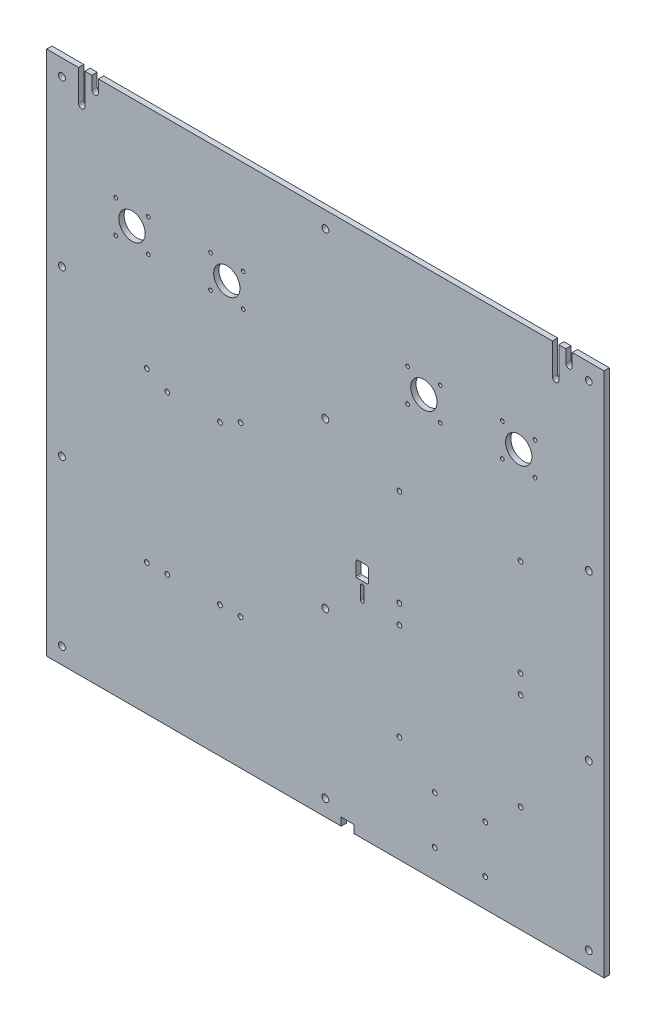
from build123d import *

# Parameters (mm, degrees)
MODEL_R             = 3.25
MODEL_R_2           = 2.25
MODEL_R_3           = 1.75
MODEL_R_4           = 12.5
BOSS_EXTRUDE1_DEPTH = 5


with BuildPart() as part:
    # Model → Boss-Extrude1 (new body)
    with BuildSketch(Plane.XY):
        with BuildLine():
            Line((-234.249986481, 220.000001375), (-234.249986481, 249.5))
            Line((-234.249986481, 249.5), (-264.5, 249.5))
            Line((-264.5, 249.5), (-264.5, -249.499999996))
            Line((-264.5, -249.499999996), (15, -249.499999996))
            Line((15, -249.499999996), (15, -241.999999996))
            Line((15, -241.999999996), (27, -241.999999996))
            Line((27, -241.999999996), (27, -249.499999996))
            Line((27, -249.499999996), (264.5, -249.499999996))
            Line((264.5, -249.499999996), (264.5, 249.5))
            Line((264.5, 249.5), (234.25, 249.5))
            Line((234.25, 249.5), (234.25, 237.5))
            ThreePointArc((234.25, 237.5), (231.25, 234.5), (228.25, 237.5))
            Line((228.25, 237.5), (228.25, 249.5))
            Line((228.25, 249.5), (221.500013519, 249.5))
            Line((221.500013519, 249.5), (221.500013519, 220.000001375))
            ThreePointArc((221.500013519, 220.000001375), (218.500013519, 217.000001375), (215.500013519, 220.000001375))
            Line((215.500013519, 220.000001375), (215.500013519, 249.5))
            Line((215.500013519, 249.5), (-215.5, 249.5))
            Line((-215.5, 249.5), (-215.5, 237.5))
            ThreePointArc((-215.5, 237.5), (-218.5, 234.5), (-221.5, 237.5))
            Line((-221.5, 237.5), (-221.5, 249.5))
            Line((-221.5, 249.5), (-228.249986481, 249.5))
            Line((-228.249986481, 249.5), (-228.249986481, 220.000001375))
            ThreePointArc((-228.249986481, 220.000001375), (-231.249986481, 217.000001375), (-234.249986481, 220.000001375))
        make_face()
        with Locations((0, 234)):
            Circle(MODEL_R, mode=Mode.SUBTRACT)
        with Locations((250, 78)):
            Circle(MODEL_R, mode=Mode.SUBTRACT)
        with Locations((250, -233.999999996)):
            Circle(MODEL_R, mode=Mode.SUBTRACT)
        with Locations((250, -77.999999996)):
            Circle(MODEL_R, mode=Mode.SUBTRACT)
        with Locations((151.75, -177.499999995)):
            Circle(MODEL_R_2, mode=Mode.SUBTRACT)
        with Locations((0, -233.999999996)):
            Circle(MODEL_R, mode=Mode.SUBTRACT)
        with Locations((0, -77.999999996)):
            Circle(MODEL_R, mode=Mode.SUBTRACT)
        with Locations((0, 78)):
            Circle(MODEL_R, mode=Mode.SUBTRACT)
        with Locations((70.25, -38.5)):
            Circle(MODEL_R_2, mode=Mode.SUBTRACT)
        with Locations((185.25, -56.5)):
            Circle(MODEL_R_2, mode=Mode.SUBTRACT)
        with Locations((185.25, -148.5)):
            Circle(MODEL_R_2, mode=Mode.SUBTRACT)
        with Locations((70.25, -148.5)):
            Circle(MODEL_R_2, mode=Mode.SUBTRACT)
        with Locations((70.25, -56.5)):
            Circle(MODEL_R_2, mode=Mode.SUBTRACT)
        with Locations((70.25, 53.5)):
            Circle(MODEL_R_2, mode=Mode.SUBTRACT)
        with Locations((185.25, 53.5)):
            Circle(MODEL_R_2, mode=Mode.SUBTRACT)
        with Locations((185.25, -38.5)):
            Circle(MODEL_R_2, mode=Mode.SUBTRACT)
        with Locations((199, 160)):
            Circle(MODEL_R_3, mode=Mode.SUBTRACT)
        with Locations((199, 129)):
            Circle(MODEL_R_3, mode=Mode.SUBTRACT)
        with Locations((168, 129)):
            Circle(MODEL_R_3, mode=Mode.SUBTRACT)
        with Locations((168, 160)):
            Circle(MODEL_R_3, mode=Mode.SUBTRACT)
        with Locations((109, 160)):
            Circle(MODEL_R_3, mode=Mode.SUBTRACT)
        with Locations((78, 129)):
            Circle(MODEL_R_3, mode=Mode.SUBTRACT)
        with Locations((78, 160)):
            Circle(MODEL_R_3, mode=Mode.SUBTRACT)
        with Locations((109, 129)):
            Circle(MODEL_R_3, mode=Mode.SUBTRACT)
        with Locations((-109, 129)):
            Circle(MODEL_R_3, mode=Mode.SUBTRACT)
        with Locations((-109, 160)):
            Circle(MODEL_R_3, mode=Mode.SUBTRACT)
        with Locations((-78, 129)):
            Circle(MODEL_R_3, mode=Mode.SUBTRACT)
        with Locations((-78, 160)):
            Circle(MODEL_R_3, mode=Mode.SUBTRACT)
        with Locations((-199, 129)):
            Circle(MODEL_R_3, mode=Mode.SUBTRACT)
        with Locations((-168, 129)):
            Circle(MODEL_R_3, mode=Mode.SUBTRACT)
        with Locations((-168, 160)):
            Circle(MODEL_R_3, mode=Mode.SUBTRACT)
        with Locations((-199, 160)):
            Circle(MODEL_R_3, mode=Mode.SUBTRACT)
        with Locations((-250, 78)):
            Circle(MODEL_R, mode=Mode.SUBTRACT)
        with Locations((-250, -77.999999996)):
            Circle(MODEL_R, mode=Mode.SUBTRACT)
        with Locations((-250, -233.999999996)):
            Circle(MODEL_R, mode=Mode.SUBTRACT)
        with Locations((-250, 234)):
            Circle(MODEL_R, mode=Mode.SUBTRACT)
        with Locations((-100, -125)):
            Circle(MODEL_R_2, mode=Mode.SUBTRACT)
        with Locations((-100, 25)):
            Circle(MODEL_R_2, mode=Mode.SUBTRACT)
        with Locations((-150, 25)):
            Circle(MODEL_R_2, mode=Mode.SUBTRACT)
        with Locations((250, 234)):
            Circle(MODEL_R, mode=Mode.SUBTRACT)
        with Locations((-150, -125)):
            Circle(MODEL_R_2, mode=Mode.SUBTRACT)
        with Locations((103.75, -177.499999995)):
            Circle(MODEL_R_2, mode=Mode.SUBTRACT)
        with Locations((-183.5, 144.5)):
            Circle(MODEL_R_4, mode=Mode.SUBTRACT)
        with Locations((-93.5, 144.5)):
            Circle(MODEL_R_4, mode=Mode.SUBTRACT)
        with Locations((93.5, 144.5)):
            Circle(MODEL_R_4, mode=Mode.SUBTRACT)
        with Locations((183.5, 144.5)):
            Circle(MODEL_R_4, mode=Mode.SUBTRACT)
        with Locations((-169.5, -125)):
            Circle(MODEL_R_2, mode=Mode.SUBTRACT)
        with Locations((-80.5, 34.5)):
            Circle(MODEL_R_2, mode=Mode.SUBTRACT)
        with Locations((-169.5, 34.5)):
            Circle(MODEL_R_2, mode=Mode.SUBTRACT)
        with Locations((-80.5, -125)):
            Circle(MODEL_R_2, mode=Mode.SUBTRACT)
        with Locations((151.75, -222.499099699)):
            Circle(MODEL_R_2, mode=Mode.SUBTRACT)
        with Locations((103.75, -222.499099699)):
            Circle(MODEL_R_2, mode=Mode.SUBTRACT)
        with BuildLine():
            Line((40, -37.999999995), (30, -37.999999995))
            ThreePointArc((30, -37.999999995), (29.292893219, -37.707106777), (29, -36.999999995))
            Line((29, -36.999999995), (29, -24.999999995))
            ThreePointArc((29, -24.999999995), (29.585786438, -23.585786433), (31, -22.999999995))
            Line((31, -22.999999995), (39, -22.999999995))
            ThreePointArc((39, -22.999999995), (40.414213562, -23.585786433), (41, -24.999999995))
            Line((41, -24.999999995), (41, -36.999999995))
            ThreePointArc((41, -36.999999995), (40.707106781, -37.707106777), (40, -37.999999995))
        make_face(mode=Mode.SUBTRACT)
        with BuildLine():
            Line((36.6, -41.999999995), (36.6, -54.499999995))
            ThreePointArc((36.6, -54.499999995), (35, -56.099999995), (33.4, -54.499999995))
            Line((33.4, -54.499999995), (33.4, -41.999999995))
            ThreePointArc((33.4, -41.999999995), (35, -40.399999995), (36.6, -41.999999995))
        make_face(mode=Mode.SUBTRACT)
    extrude(amount=BOSS_EXTRUDE1_DEPTH)


solid = part.part
